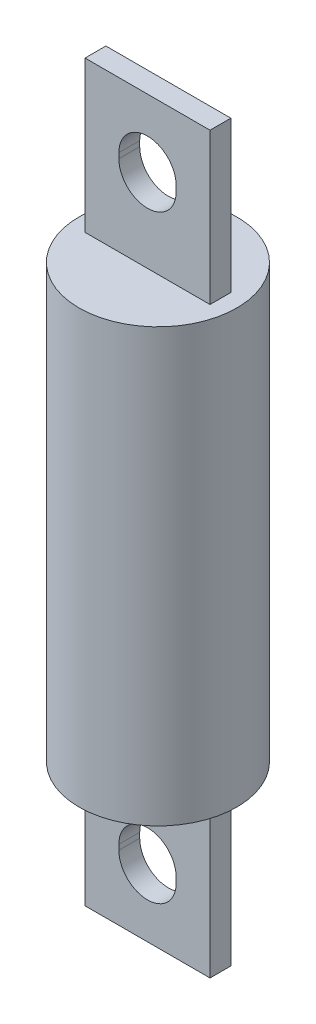
from build123d import *

# Parameters (mm, degrees)
SKETCH1_R           = 12.0269
BOSS_EXTRUDE1_DEPTH = 65.8876
SKETCH2_W           = 19.05
SKETCH2_H           = 3.175
BOSS_EXTRUDE2_DEPTH = 23.0124
CUT_EXTRUDE1_DEPTH  = 14.6144


with BuildPart() as part:
    # Sketch1 → Boss-Extrude1 (new body)
    with BuildSketch(Plane(origin=(0, 0, 0), x_dir=(1, 0, 0), z_dir=(0, 1, 0))):
        Circle(SKETCH1_R)
    extrude(amount=BOSS_EXTRUDE1_DEPTH)

    # Sketch2 → Boss-Extrude2 (add)
    with BuildSketch(Plane(origin=(0, 65.8876, 0), x_dir=(1, 0, 0), z_dir=(0, 1, 0))):
        Rectangle(SKETCH2_W, SKETCH2_H)
    boss_extrude2 = extrude(amount=BOSS_EXTRUDE2_DEPTH)

    # Sketch3 → Cut-Extrude1 (cut, through all)
    with BuildSketch(Plane.XY.offset(1.5875)):
        with BuildLine():
            Line((-4.3688, 78.98511), (-4.3688, 78.1939))
            ThreePointArc((-4.3688, 78.1939), (0, 73.8251), (4.3688, 78.1939))
            Line((4.3688, 78.1939), (4.3688, 78.98511))
            ThreePointArc((4.3688, 78.98511), (0, 83.35391), (-4.3688, 78.98511))
        make_face()
    cut_extrude1 = extrude(amount=-CUT_EXTRUDE1_DEPTH, mode=Mode.SUBTRACT)

    # Mirror2: Boss-Extrude2, Cut-Extrude1 across plane
    add(boss_extrude2.mirror(Plane.ZX.offset(32.9438)))
    add(cut_extrude1.mirror(Plane.ZX.offset(32.9438)), mode=Mode.SUBTRACT)


solid = part.part
